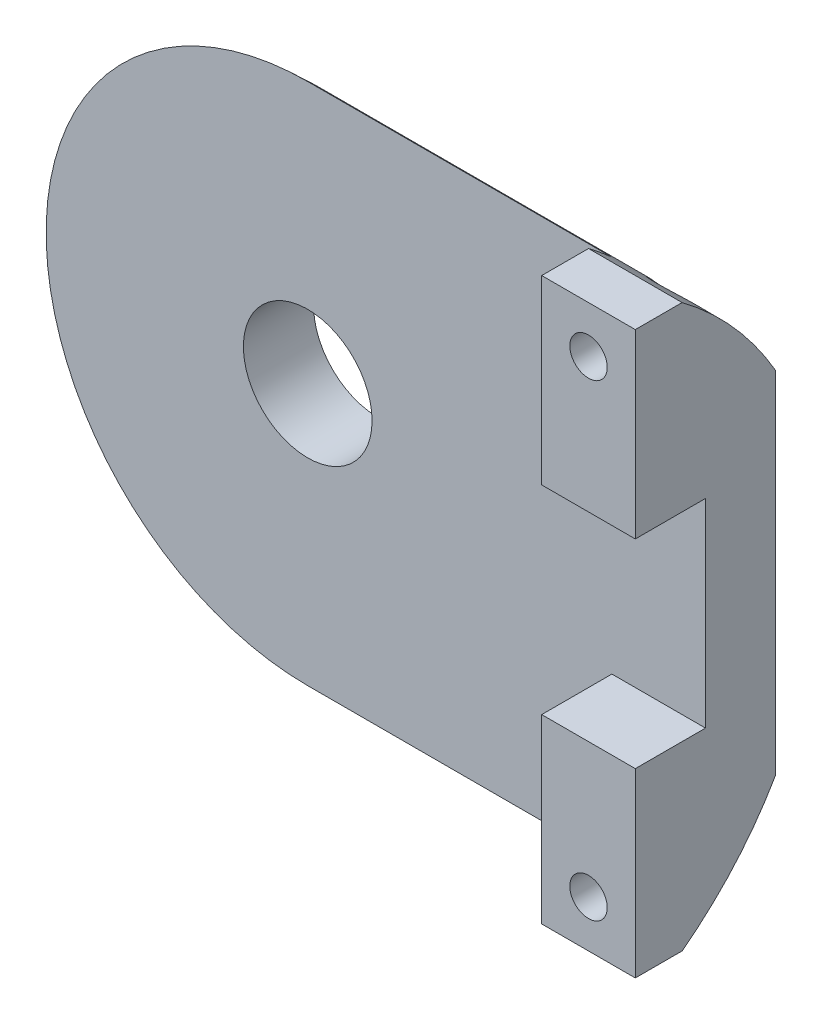
from build123d import *

# Parameters (mm, degrees)
SKETCH1_R           = 2.75
BOSS_EXTRUDE1_DEPTH = 6
BODY_START          = 3
SKETCH2_R           = 2.75
BODY_HOLE_DEPTH     = 3
CUT_EXTRUDE2_DEPTH  = 23.226110771
CUT_REVOLVE1_ANGLE  = 180
SKETCH7_R           = 0.8
SCREW_HOLES_DEPTH   = 22.656407828
SKETCH9_R           = 1.25
SCREW_HEADS_DEPTH   = 4


with BuildPart() as part:
    # Sketch1 → Boss-Extrude1 (new body)
    with BuildSketch(Plane.XY):
        with BuildLine():
            Line((17, -12), (17, 12))
            Line((17, 12), (5, 12))
            ThreePointArc((5, 12), (-13, 0), (5, -12))
            Line((5, -12), (17, -12))
        make_face()
        Circle(SKETCH1_R, mode=Mode.SUBTRACT)
    extrude(amount=BOSS_EXTRUDE1_DEPTH)

    # Sketch2 → Body Hole (cut)
    with BuildSketch(Plane.XY.offset(BODY_START)):
        with BuildLine():
            ThreePointArc((5, 12), (-13, 0), (5, -12))
            Line((5, -12), (13, -12))
            Line((13, -12), (13, -4.25))
            Line((13, -4.25), (17, -4.25))
            Line((17, -4.25), (17, 4.25))
            Line((17, 4.25), (13, 4.25))
            Line((13, 4.25), (13, 12))
            Line((13, 12), (5, 12))
        make_face()
        Circle(SKETCH2_R, mode=Mode.SUBTRACT)
    extrude(amount=BODY_HOLE_DEPTH, mode=Mode.SUBTRACT)

    # Sketch3 → Cut-Extrude2 (cut, through all)
    with BuildSketch(Plane(origin=(0, 0, 0), x_dir=(0, 0, -1), z_dir=(1, 0, 0))):
        with BuildLine():
            Line((2, 15), (-13, 15))
            ThreePointArc((-13, 15), (-2.393398282, 10.606601718), (2, 0))
            Line((2, 0), (2, 15))
        make_face()
        with BuildLine():
            Line((2, -15), (2, 0))
            ThreePointArc((2, 0), (-2.393398282, -10.606601718), (-13, -15))
            Line((-13, -15), (2, -15))
        make_face()
    extrude(amount=CUT_EXTRUDE2_DEPTH, mode=Mode.SUBTRACT)

    # Sketch6 → Cut-Revolve1 (revolve, cut)
    with BuildSketch(Plane(origin=(0, 0, 0), x_dir=(0, 0, -1), z_dir=(1, 0, 0))):
        with BuildLine():
            Line((1, 15), (-13, 15))
            ThreePointArc((-13, 15), (-4.508164866, 12.36481848), (1, 5.385164807))
            Line((1, 5.385164807), (2, 5.385164807))
            Line((2, 5.385164807), (2, 15))
            Line((2, 15), (1, 15))
        make_face()
    revolve(axis=Axis((0, 0, 0), (0, 0, 1)), revolution_arc=CUT_REVOLVE1_ANGLE, mode=Mode.SUBTRACT)

    # Sketch7 → Screw Holes (cut, through all)
    with BuildSketch(Plane.XY):
        with Locations(Location((15, 10, 0), (0, 0, 180))):
            Circle(SKETCH7_R)
        with Locations(Location((15, -10, 0), (0, 0, 180))):
            Circle(SKETCH7_R)
    extrude(amount=SCREW_HOLES_DEPTH, mode=Mode.SUBTRACT)

    # Sketch9 → Screw Heads (cut)
    with BuildSketch(Plane.XY):
        with Locations(Location((15, 10, 0), (0, 0, 180))):
            Circle(SKETCH9_R)
    extrude(amount=SCREW_HEADS_DEPTH, mode=Mode.SUBTRACT)


solid = part.part
